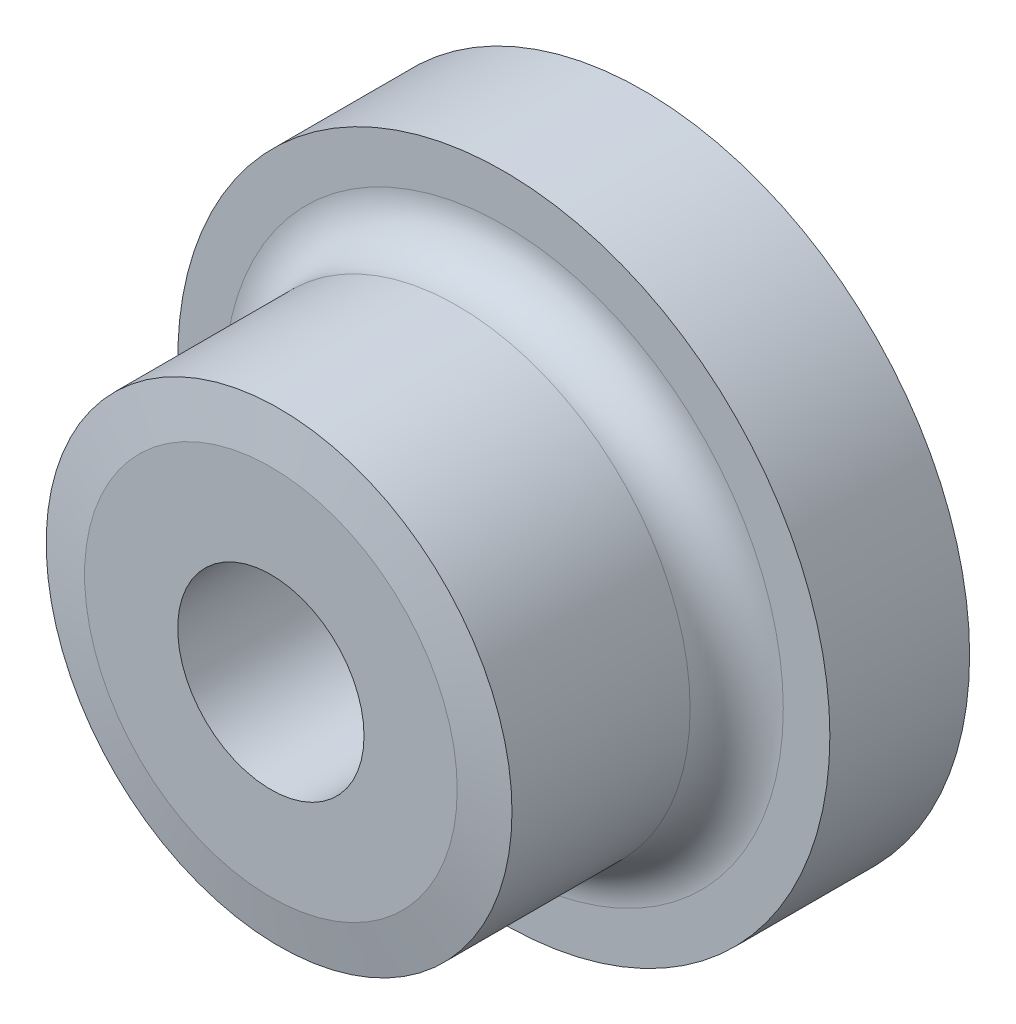
from build123d import *

# Parameters (mm, degrees)
ESQUISSE1_R             = 7
BOSS_EXTRU_1_DEPTH      = 3
ESQUISSE2_R             = 5
BOSS_EXTRU_2_DEPTH      = 5
ESQUISSE3_R             = 2
ENL_V_MAT_EXTRU_1_DEPTH = 9
CONG_1_R                = 1
CHANFREIN1_SIZE         = 1
CHANFREIN1_SIZE2        = 0.176326981


with BuildPart() as part:
    # Esquisse1 → Boss.-Extru.1 (new body)
    with BuildSketch(Plane.XY):
        Circle(ESQUISSE1_R)
    extrude(amount=BOSS_EXTRU_1_DEPTH)

    # Esquisse2 → Boss.-Extru.2 (add)
    with BuildSketch(Plane.XY.offset(3)):
        Circle(ESQUISSE2_R)
    extrude(amount=BOSS_EXTRU_2_DEPTH)

    # Esquisse3 → Enlèv. mat.-Extru.1 (cut, through all)
    with BuildSketch(Plane.XY.offset(8)):
        Circle(ESQUISSE3_R)
    extrude(amount=-ENL_V_MAT_EXTRU_1_DEPTH, mode=Mode.SUBTRACT)

    # Congé1
    cong_1_edges = [part.edges().sort_by_distance(p)[0] for p in [
        (-5, 0, 3),
    ]]
    fillet(cong_1_edges, radius=CONG_1_R)

    # Chanfrein1
    chanfrein1_edges = [part.edges().sort_by_distance(p)[0] for p in [
        (-5, 0, 8),
    ]]
    chanfrein1_side = [part.faces().sort_by_distance(p)[0] for p in [
        (-4.858578644, 0, 8),
    ]]
    chamfer(chanfrein1_edges, length=CHANFREIN1_SIZE, length2=CHANFREIN1_SIZE2, reference=chanfrein1_side[0])


solid = part.part
